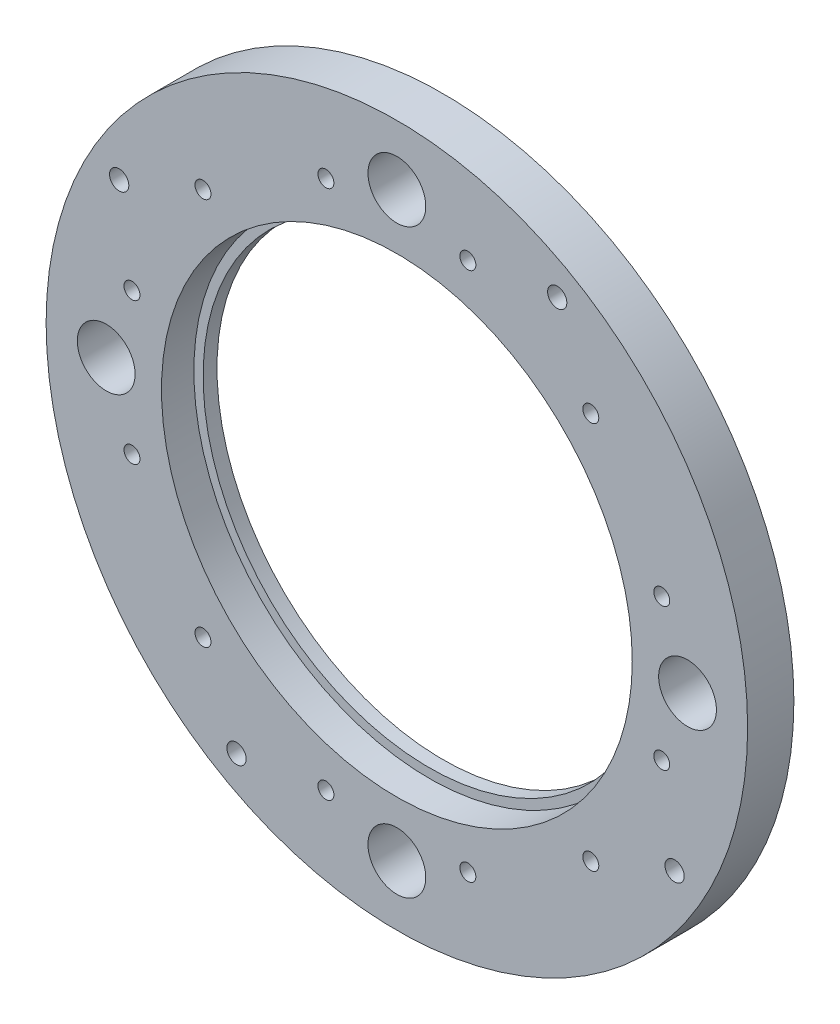
from build123d import *

# Parameters (mm, degrees)
SKETCH1_W                                = 75.85
SKETCH1_H                                = 10
M3_5_CLEARANCE_HOLE1_D                   = 4.1656
M3_5_CLEARANCE_HOLE1_DEPTH               = 10
M3_CLEARANCE_HOLE1_D                     = 3.4544
M3_CLEARANCE_HOLE1_DEPTH                 = 10
F_12_5_12_5_DIAMETER_HOLE1_D             = 12.5
F_12_5_12_5_DIAMETER_HOLE1_DEPTH         = 10
CBORE_FOR_M90_HEX_HEAD_BOLT1_D           = 97.8
CBORE_FOR_M90_HEX_HEAD_BOLT1_DEPTH       = 10
CBORE_FOR_M90_HEX_HEAD_BOLT1_CBORE_D     = 101.8
CBORE_FOR_M90_HEX_HEAD_BOLT1_CBORE_DEPTH = 7


with BuildPart() as part:
    # Sketch1 → Revolve1 (revolve)
    with BuildSketch(Plane.XZ):
        with Locations((37.925, 0)):
            Rectangle(SKETCH1_W, SKETCH1_H)
    revolve(axis=Axis((0, 0, 5), (0, 0, -1)))

    # M3.5 Clearance Hole1
    with Locations(Plane(origin=(0, 0, -5), x_dir=(-1, 0, 0), z_dir=(0, 0, -1))):
        with Locations((60.051933549, 34.671), (-34.671, 60.051933549), (-60.051933549, -34.671), (34.671, -60.051933549)):
            Hole(M3_5_CLEARANCE_HOLE1_D / 2, depth=M3_5_CLEARANCE_HOLE1_DEPTH)

    # M3 Clearance Hole1
    with Locations(Plane(origin=(0, 0, -5), x_dir=(-1, 0, 0), z_dir=(0, 0, -1))):
        with Locations((41.931432124, 41.931432124), (57.279401499, 15.347969375), (57.279401499, -15.347969375), (41.931432124, -41.931432124), (15.347969375, -57.279401499), (-15.347969375, -57.279401499), (-41.931432124, -41.931432124), (-57.279401499, -15.347969375), (-57.279401499, 15.347969375), (-41.931432124, 41.931432124), (-15.347969375, 57.279401499), (15.347969375, 57.279401499)):
            Hole(M3_CLEARANCE_HOLE1_D / 2, depth=M3_CLEARANCE_HOLE1_DEPTH)

    # Ø12.5 (12.5) Diameter Hole1
    with Locations(Plane(origin=(0, 0, -5), x_dir=(-1, 0, 0), z_dir=(0, 0, -1))):
        with Locations((62.85, 0), (0, -62.85), (-62.85, 0), (0, 62.85)):
            Hole(F_12_5_12_5_DIAMETER_HOLE1_D / 2, depth=F_12_5_12_5_DIAMETER_HOLE1_DEPTH)

    # CBORE for M90 Hex Head Bolt1
    with Locations(Plane.XY.offset(5)):
        with Locations((0, 0)):
            CounterBoreHole(CBORE_FOR_M90_HEX_HEAD_BOLT1_D / 2, CBORE_FOR_M90_HEX_HEAD_BOLT1_CBORE_D / 2, CBORE_FOR_M90_HEX_HEAD_BOLT1_CBORE_DEPTH, depth=CBORE_FOR_M90_HEX_HEAD_BOLT1_DEPTH)


solid = part.part
